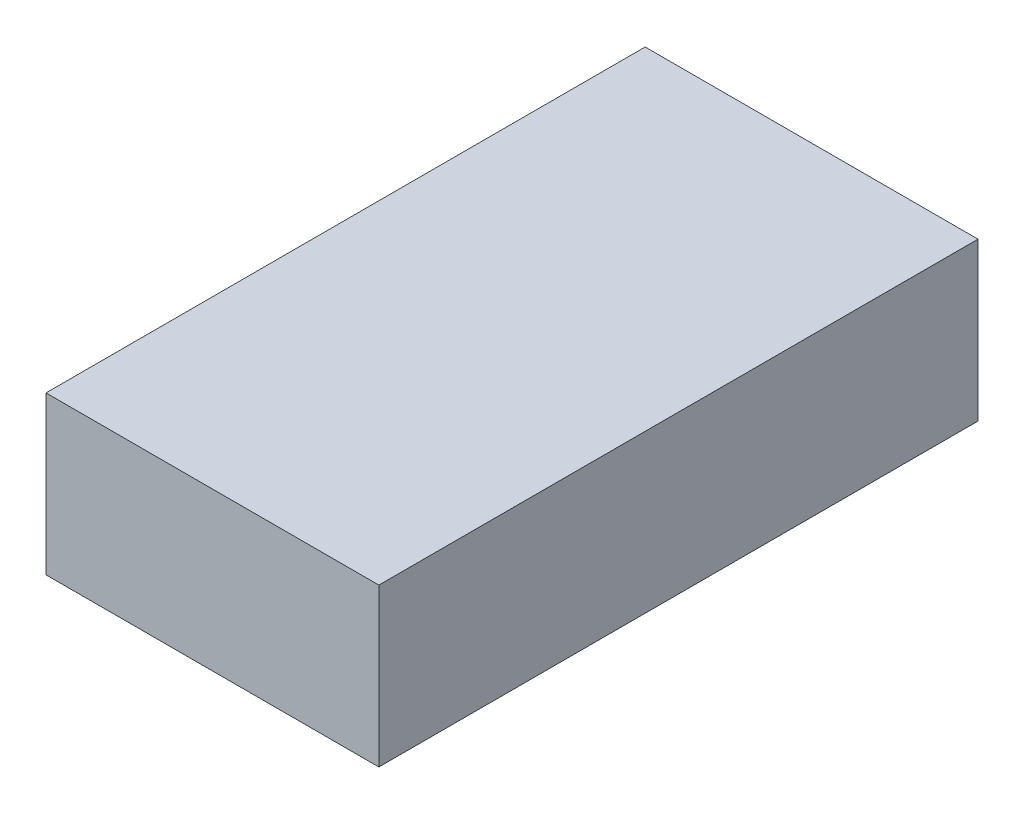
from build123d import *

# Parameters (mm, degrees)
SKETCH1_W           = 38.1
SKETCH1_H           = 68.58
BOSS_EXTRUDE1_DEPTH = 18.034


with BuildPart() as part:
    # Sketch1 → Boss-Extrude1 (new body)
    with BuildSketch(Plane(origin=(0, 0, 0), x_dir=(1, 0, 0), z_dir=(0, 1, 0))):
        with Locations((19.05, 34.29)):
            Rectangle(SKETCH1_W, SKETCH1_H)
    extrude(amount=BOSS_EXTRUDE1_DEPTH)


solid = part.part
